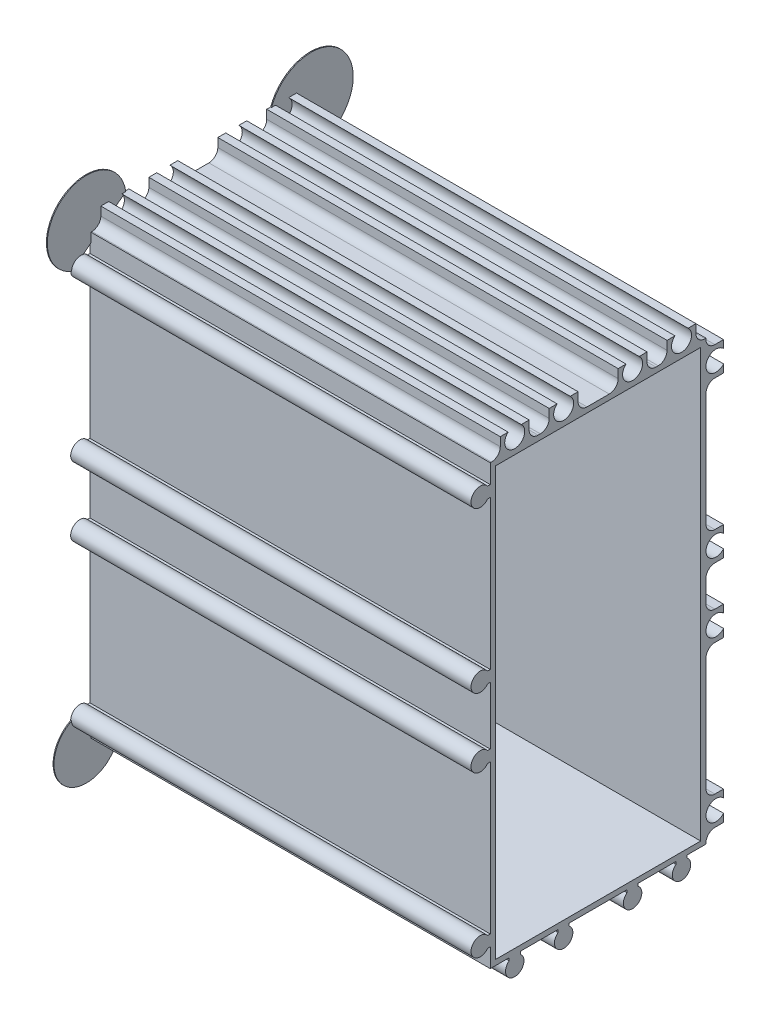
from build123d import *

# Parameters (mm, degrees)
EXTRUDE_1_DEPTH             = 90
SKETCH_2_W                  = 90
SKETCH_2_H                  = 44.25
EXTRUDE_2_DEPTH             = 8.2
SKETCH_3_W                  = 90
SKETCH_3_H                  = 102.45
EXTRUDE_3_DEPTH             = 8.2
SKETCH_4_W                  = 4.5
SKETCH_4_H                  = 3.95
CUT_EXTRUDE_1_DEPTH         = 91
SKETCH_5_W                  = 2.25
SKETCH_5_H                  = 3.95
CUT_EXTRUDE_2_DEPTH         = 91
SKETCH_6_W                  = 3.95
SKETCH_6_H                  = 2.25
CUT_EXTRUDE_3_DEPTH         = 91
SKETCH_7_W                  = 3.95
SKETCH_7_H                  = 29.5
CUT_EXTRUDE_4_DEPTH         = 91
SKETCH_8_W                  = 3.95
SKETCH_8_H                  = 9
CUT_EXTRUDE_5_DEPTH         = 91
SKETCH_9_W                  = 3.95
SKETCH_9_H                  = 29.5
CUT_EXTRUDE_6_DEPTH         = 91
SKETCH_10_W                 = 3.95
SKETCH_10_H                 = 6.2
CUT_EXTRUDE_7_DEPTH         = 91
SKETCH_11_W                 = 2.25
SKETCH_11_H                 = 3.95
CUT_EXTRUDE_8_DEPTH         = 91
SKETCH_12_W                 = 4.5
SKETCH_12_H                 = 3.95
CUT_EXTRUDE_9_DEPTH         = 91
SKETCH_13_W                 = 9
SKETCH_13_H                 = 3.95
CUT_EXTRUDE_10_DEPTH        = 91
SKETCH_14_W                 = 46.1
SKETCH_14_H                 = 96.1
CUT_EXTRUDE_11_DEPTH        = 86.6
HOLE_WIZARD_2_5_2_5_1_D     = 2.5
HOLE_WIZARD_2_5_2_5_1_DEPTH = 90
HOLE_WIZARD_4_5_4_5_1_D     = 4.5
HOLE_WIZARD_4_5_4_5_1_DEPTH = 90
SKETCH_22_R                 = 1.631577579
SKETCH_22_R_2               = 1.519375383
SKETCH_22_R_3               = 1.487580747
SKETCH_22_R_4               = 1.581735942
SKETCH_22_R_5               = 1.487835557
SKETCH_22_R_6               = 1.42600834
SKETCH_22_R_7               = 1.628129915
SKETCH_22_R_8               = 1.52367125
EXTRUDE_4_DEPTH             = 90
FILLET_5_R                  = 2
FILLET_6_R                  = 2
FILLET_7_R                  = 2
FILLET_8_R                  = 2
FILLET_9_R                  = 2
FILLET_10_R                 = 2
FILLET_11_R                 = 2
FILLET_12_R                 = 2
FILLET_13_R                 = 2
FILLET_14_R                 = 2
FILLET_15_R                 = 2
FILLET_16_R                 = 2
FILLET_17_R                 = 2
FILLET_18_R                 = 2
FILLET_19_R                 = 2
FILLET_20_R                 = 2
EXTRUDE_6_DEPTH             = 0.2


with BuildPart() as part:
    # Эскиз1 → Бобышка-Вытянуть1 (new body)
    with BuildSketch(Plane(origin=(90, 0, 0), x_dir=(0, 0, -1), z_dir=(1, 0, 0))):
        with BuildLine():
            Line((6.75, 225.906238208), (6.75, 320.75))
            Line((6.75, 320.75), (-38.093761792, 320.75))
            ThreePointArc((-38.093761792, 320.75), (-41.825, 319.5), (-38.093761792, 318.25))
            Line((-38.093761792, 318.25), (-37.5, 318.25))
            Line((-37.5, 318.25), (-37.5, 284.75))
            Line((-37.5, 284.75), (-38.093761792, 284.75))
            ThreePointArc((-38.093761792, 284.75), (-41.825, 283.5), (-38.093761792, 282.25))
            Line((-38.093761792, 282.25), (-37.5, 282.25))
            Line((-37.5, 282.25), (-37.5, 269.25))
            Line((-37.5, 269.25), (-38.093761792, 269.25))
            ThreePointArc((-38.093761792, 269.25), (-41.825, 268), (-38.093761792, 266.75))
            Line((-38.093761792, 266.75), (-37.5, 266.75))
            Line((-37.5, 266.75), (-37.5, 233.25))
            Line((-37.5, 233.25), (-38.093761792, 233.25))
            ThreePointArc((-38.093761792, 233.25), (-41.825, 232), (-38.093761792, 230.75))
            Line((-38.093761792, 230.75), (-37.5, 230.75))
            Line((-37.5, 230.75), (-37.5, 226.5))
            Line((-37.5, 226.5), (-33.25, 226.5))
            Line((-33.25, 226.5), (-33.25, 225.906238208))
            ThreePointArc((-33.25, 225.906238208), (-32, 222.175), (-30.75, 225.906238208))
            Line((-30.75, 225.906238208), (-30.75, 226.5))
            Line((-30.75, 226.5), (-22.25, 226.5))
            Line((-22.25, 226.5), (-22.25, 225.906238208))
            ThreePointArc((-22.25, 225.906238208), (-21, 222.175), (-19.75, 225.906238208))
            Line((-19.75, 225.906238208), (-19.75, 226.5))
            Line((-19.75, 226.5), (-6.75, 226.5))
            Line((-6.75, 226.5), (-6.75, 225.906238208))
            ThreePointArc((-6.75, 225.906238208), (-5.5, 222.175), (-4.25, 225.906238208))
            Line((-4.25, 225.906238208), (-4.25, 226.5))
            Line((-4.25, 226.5), (4.25, 226.5))
            Line((4.25, 226.5), (4.25, 225.906238208))
            ThreePointArc((4.25, 225.906238208), (5.5, 222.175), (6.75, 225.906238208))
        make_face()
    extrude(amount=-EXTRUDE_1_DEPTH)

    # Эскиз2 → Бобышка-Вытянуть2 (add)
    with BuildSketch(Plane(origin=(0, 320.75, 0), x_dir=(-1, 0, 0), z_dir=(0, 1, 0))):
        with Locations((-45, 15.375)):
            Rectangle(SKETCH_2_W, SKETCH_2_H)
    extrude(amount=EXTRUDE_2_DEPTH)

    # Эскиз3 → Бобышка-Вытянуть3 (add)
    with BuildSketch(Plane(origin=(0, 0, -6.75), x_dir=(-1, 0, 0), z_dir=(0, 0, -1))):
        with Locations((-45, 277.725)):
            Rectangle(SKETCH_3_W, SKETCH_3_H)
    extrude(amount=EXTRUDE_3_DEPTH)

    # Эскиз4 → Вырез-Вытянуть1 (cut, through all)
    with BuildSketch(Plane.ZY):
        with Locations((26.5, 326.975)):
            Rectangle(SKETCH_4_W, SKETCH_4_H)
    extrude(amount=-CUT_EXTRUDE_1_DEPTH, mode=Mode.SUBTRACT)

    # Эскиз5 → Вырез-Вытянуть2 (cut, through all)
    with BuildSketch(Plane.ZY):
        with Locations((36.375, 326.975)):
            Rectangle(SKETCH_5_W, SKETCH_5_H)
    extrude(amount=-CUT_EXTRUDE_2_DEPTH, mode=Mode.SUBTRACT)

    # Эскиз6 → Вырез-Вытянуть3 (cut, through all)
    with BuildSketch(Plane.ZY):
        with Locations((-12.975, 227.625)):
            Rectangle(SKETCH_6_W, SKETCH_6_H)
    extrude(amount=-CUT_EXTRUDE_3_DEPTH, mode=Mode.SUBTRACT)

    # Эскиз7 → Вырез-Вытянуть4 (cut, through all)
    with BuildSketch(Plane.ZY):
        with Locations((-12.975, 250)):
            Rectangle(SKETCH_7_W, SKETCH_7_H)
    extrude(amount=-CUT_EXTRUDE_4_DEPTH, mode=Mode.SUBTRACT)

    # Эскиз8 → Вырез-Вытянуть5 (cut, through all)
    with BuildSketch(Plane.ZY):
        with Locations((-12.975, 275.75)):
            Rectangle(SKETCH_8_W, SKETCH_8_H)
    extrude(amount=-CUT_EXTRUDE_5_DEPTH, mode=Mode.SUBTRACT)

    # Эскиз9 → Вырез-Вытянуть6 (cut, through all)
    with BuildSketch(Plane.ZY):
        with Locations((-12.975, 301.5)):
            Rectangle(SKETCH_9_W, SKETCH_9_H)
    extrude(amount=-CUT_EXTRUDE_6_DEPTH, mode=Mode.SUBTRACT)

    # Эскиз10 → Вырез-Вытянуть7 (cut, through all)
    with BuildSketch(Plane.ZY):
        with Locations((-12.975, 325.85)):
            Rectangle(SKETCH_10_W, SKETCH_10_H)
    extrude(amount=-CUT_EXTRUDE_7_DEPTH, mode=Mode.SUBTRACT)

    # Эскиз11 → Вырез-Вытянуть8 (cut, through all)
    with BuildSketch(Plane.ZY):
        with Locations((-9.875, 326.975)):
            Rectangle(SKETCH_11_W, SKETCH_11_H)
    extrude(amount=-CUT_EXTRUDE_8_DEPTH, mode=Mode.SUBTRACT)

    # Эскиз12 → Вырез-Вытянуть9 (cut, through all)
    with BuildSketch(Plane.ZY):
        with Locations((0, 326.975)):
            Rectangle(SKETCH_12_W, SKETCH_12_H)
    extrude(amount=-CUT_EXTRUDE_9_DEPTH, mode=Mode.SUBTRACT)

    # Эскиз13 → Вырез-Вытянуть10 (cut, through all)
    with BuildSketch(Plane.ZY):
        with Locations((13.25, 326.975)):
            Rectangle(SKETCH_13_W, SKETCH_13_H)
    extrude(amount=-CUT_EXTRUDE_10_DEPTH, mode=Mode.SUBTRACT)

    # Эскиз14 → Вырез-Вытянуть11 (cut)
    with BuildSketch(Plane(origin=(90, 0, 0), x_dir=(0, 0, -1), z_dir=(1, 0, 0))):
        with Locations((-13.25, 275.75)):
            Rectangle(SKETCH_14_W, SKETCH_14_H)
    extrude(amount=-CUT_EXTRUDE_11_DEPTH, mode=Mode.SUBTRACT)

    # Диаметр отверстия Ø2.5 (2.5)1
    with Locations(Plane(origin=(90, 0, 0), x_dir=(0, 0, -1), z_dir=(1, 0, 0))):
        with Locations((-39.75, 232), (-21, 224.25), (-39.75, 283.5), (-5.5, 224.25), (5.5, 224.25), (-39.75, 319.5), (-39.75, 268), (-32, 224.25)):
            Hole(HOLE_WIZARD_2_5_2_5_1_D / 2, depth=HOLE_WIZARD_2_5_2_5_1_DEPTH)

    # Диаметр отверстия Ø4.5 (4.5)1
    with Locations(Plane.ZY):
        with Locations((21, 327.25), (32, 327.25), (-13.25, 232), (-13.25, 268), (-13.25, 283.5), (-13.25, 319.5), (-5.5, 327.25), (5.5, 327.25)):
            Hole(HOLE_WIZARD_4_5_4_5_1_D / 2, depth=HOLE_WIZARD_4_5_4_5_1_DEPTH)

    # Эскиз22 → Бобышка-Вытянуть4 (add)
    with BuildSketch(Plane(origin=(90, 0, 0), x_dir=(0, 0, -1), z_dir=(1, 0, 0))):
        with Locations((-39.75, 319.5)):
            Circle(SKETCH_22_R)
        with Locations((-39.75, 283.5)):
            Circle(SKETCH_22_R_2)
        with Locations((-39.75, 268)):
            Circle(SKETCH_22_R_3)
        with Locations((-39.75, 232)):
            Circle(SKETCH_22_R_4)
        with Locations((-32, 224.25)):
            Circle(SKETCH_22_R_5)
        with Locations((-21, 224.25)):
            Circle(SKETCH_22_R_6)
        with Locations((-5.5, 224.25)):
            Circle(SKETCH_22_R_7)
        with Locations((5.5, 224.25)):
            Circle(SKETCH_22_R_8)
    extrude(amount=-EXTRUDE_4_DEPTH)

    # Скругление5
    fillet_5_edges = [part.edges().sort_by_distance(p)[0] for p in [
        (45, 325, 35.25),
    ]]
    fillet(fillet_5_edges, radius=FILLET_5_R)

    # Скругление6
    fillet_6_edges = [part.edges().sort_by_distance(p)[0] for p in [
        (45, 325, 28.75),
    ]]
    fillet(fillet_6_edges, radius=FILLET_6_R)

    # Скругление7
    fillet_7_edges = [part.edges().sort_by_distance(p)[0] for p in [
        (45, 325, 24.25),
    ]]
    fillet(fillet_7_edges, radius=FILLET_7_R)

    # Скругление8
    fillet_8_edges = [part.edges().sort_by_distance(p)[0] for p in [
        (45, 325, 17.75),
    ]]
    fillet(fillet_8_edges, radius=FILLET_8_R)

    # Скругление9
    fillet_9_edges = [part.edges().sort_by_distance(p)[0] for p in [
        (45, 325, 8.75),
    ]]
    fillet(fillet_9_edges, radius=FILLET_9_R)

    # Скругление10
    fillet_10_edges = [part.edges().sort_by_distance(p)[0] for p in [
        (45, 325, 2.25),
    ]]
    fillet(fillet_10_edges, radius=FILLET_10_R)

    # Скругление11
    fillet_11_edges = [part.edges().sort_by_distance(p)[0] for p in [
        (45, 325, -2.25),
    ]]
    fillet(fillet_11_edges, radius=FILLET_11_R)

    # Скругление12
    fillet_12_edges = [part.edges().sort_by_distance(p)[0] for p in [
        (45, 325, -8.75),
    ]]
    fillet(fillet_12_edges, radius=FILLET_12_R)

    # Скругление13
    fillet_13_edges = [part.edges().sort_by_distance(p)[0] for p in [
        (45, 322.75, -11),
    ]]
    fillet(fillet_13_edges, radius=FILLET_13_R)

    # Скругление14
    fillet_14_edges = [part.edges().sort_by_distance(p)[0] for p in [
        (45, 316.25, -11),
    ]]
    fillet(fillet_14_edges, radius=FILLET_14_R)

    # Скругление15
    fillet_15_edges = [part.edges().sort_by_distance(p)[0] for p in [
        (45, 286.75, -11),
    ]]
    fillet(fillet_15_edges, radius=FILLET_15_R)

    # Скругление16
    fillet_16_edges = [part.edges().sort_by_distance(p)[0] for p in [
        (45, 280.25, -11),
    ]]
    fillet(fillet_16_edges, radius=FILLET_16_R)

    # Скругление17
    fillet_17_edges = [part.edges().sort_by_distance(p)[0] for p in [
        (45, 271.25, -11),
    ]]
    fillet(fillet_17_edges, radius=FILLET_17_R)

    # Скругление18
    fillet_18_edges = [part.edges().sort_by_distance(p)[0] for p in [
        (45, 264.75, -11),
    ]]
    fillet(fillet_18_edges, radius=FILLET_18_R)

    # Скругление19
    fillet_19_edges = [part.edges().sort_by_distance(p)[0] for p in [
        (45, 235.25, -11),
    ]]
    fillet(fillet_19_edges, radius=FILLET_19_R)

    # Скругление20
    fillet_20_edges = [part.edges().sort_by_distance(p)[0] for p in [
        (45, 228.75, -11),
    ]]
    fillet(fillet_20_edges, radius=FILLET_20_R)

    # Эскиз23 → Бобышка-Вытянуть6 (add)
    with BuildSketch(Plane.ZY):
        with BuildLine():
            Line((-14.95, 316.81563549), (-3.138029851, 328.95))
            ThreePointArc((-3.138029851, 328.95), (-18.81411193, 332.393335916), (-14.95, 316.81563549))
        make_face()
        with BuildLine():
            Line((41.825, 319.5), (29.638029851, 328.95))
            ThreePointArc((29.638029851, 328.95), (43.851377387, 334.69658957), (41.825, 319.5))
        make_face()
        with BuildLine():
            Line((-14.95, 234.361970149), (-5.5, 222.175))
            ThreePointArc((-5.5, 222.175), (-19.166722881, 221.33490928), (-14.95, 234.361970149))
        make_face()
        with BuildLine():
            Line((32, 222.175), (41.825, 232))
            ThreePointArc((41.825, 232), (43.643106303, 220.356893697), (32, 222.175))
        make_face()
    extrude(amount=-EXTRUDE_6_DEPTH)


solid = part.part
